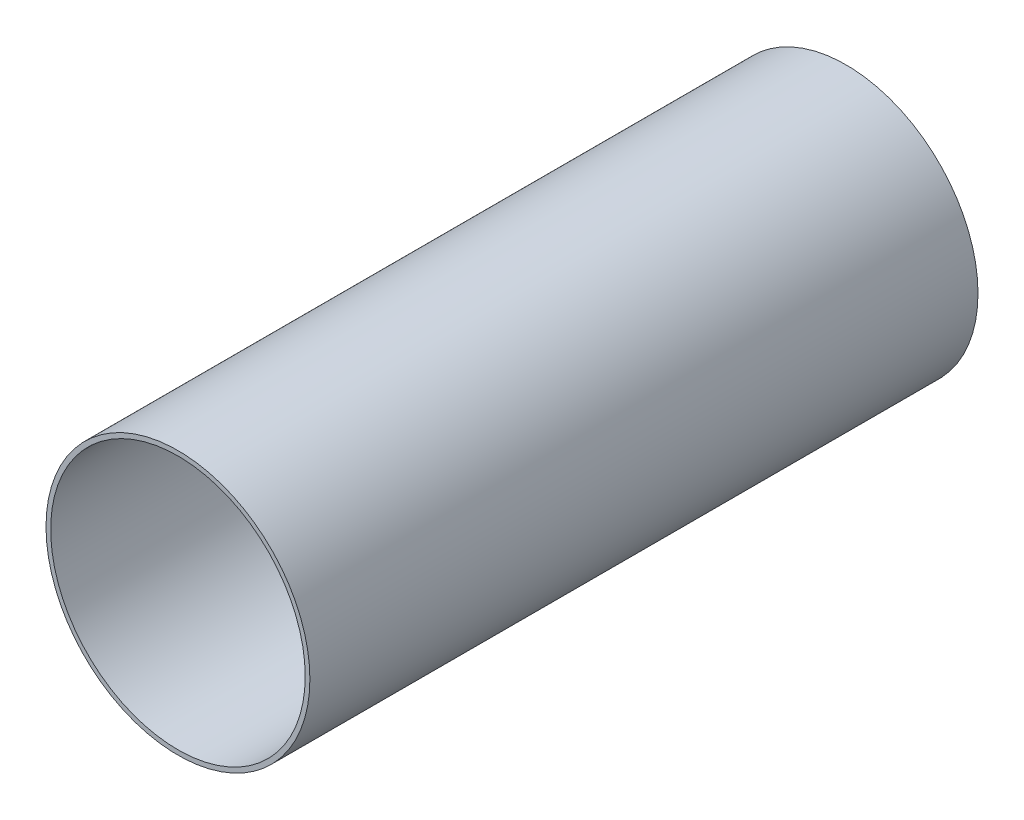
from build123d import *

# Parameters (mm, degrees)
SKETCH1_R           = 39.5
SKETCH1_R_2         = 38.1
BOSS_EXTRUDE1_DEPTH = 200


with BuildPart() as part:
    # Sketch1 → Boss-Extrude1 (new body)
    with BuildSketch(Plane.XY):
        Circle(SKETCH1_R)
        Circle(SKETCH1_R_2, mode=Mode.SUBTRACT)
    extrude(amount=BOSS_EXTRUDE1_DEPTH)


solid = part.part
